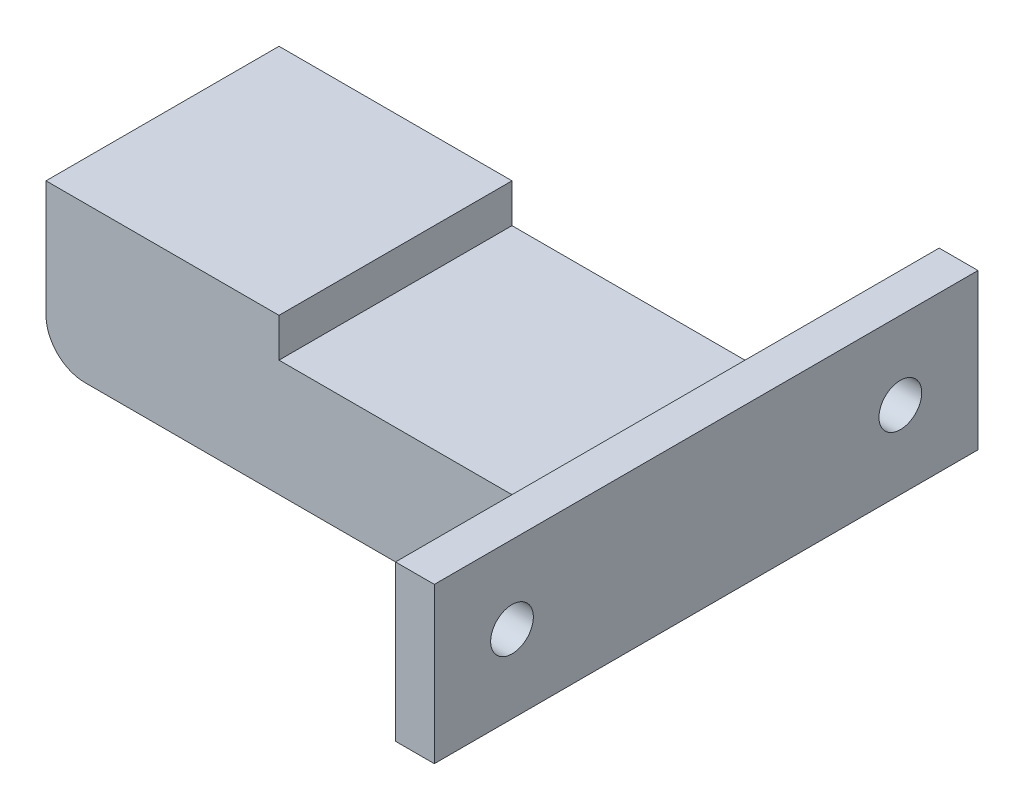
from build123d import *

# Parameters (mm, degrees)
SKETCH1_W           = 70
SKETCH1_H           = 30
BOSS_EXTRUDE1_DEPTH = 20
SKETCH8_W           = 20
SKETCH8_H           = 20
SKETCH8_R           = 2.75
BOSS_EXTRUDE5_DEPTH = 5
FILLET3_R           = 5
SKETCH9_W           = 35
SKETCH9_H           = 40
CUT_EXTRUDE5_DEPTH  = 5


with BuildPart() as part:
    # Sketch1 → Boss-Extrude1 (new body)
    with BuildSketch(Plane(origin=(0, 0, 0), x_dir=(1, 0, 0), z_dir=(0, 1, 0))):
        with Locations((35, 15)):
            Rectangle(SKETCH1_W, SKETCH1_H)
    extrude(amount=BOSS_EXTRUDE1_DEPTH)

    # Sketch8 → Boss-Extrude5 (add)
    with BuildSketch(Plane(origin=(70, 0, 0), x_dir=(0, 0, -1), z_dir=(1, 0, 0))):
        with Locations((-10, 10)):
            Rectangle(SKETCH8_W, SKETCH8_H)
        with Locations((-10, 10)):
            Circle(SKETCH8_R, mode=Mode.SUBTRACT)
    boss_extrude5 = extrude(amount=-BOSS_EXTRUDE5_DEPTH)

    # Mirror1: Boss-Extrude5 across plane
    add(boss_extrude5.mirror(Plane.XY.offset(-15)))

    # Fillet3
    fillet3_edges = [part.edges().sort_by_distance(p)[0] for p in [
        (65, 10, 0),
        (65, 10, -30),
        (0, 0, -15),
    ]]
    fillet(fillet3_edges, radius=FILLET3_R)

    # Sketch9 → Cut-Extrude5 (cut)
    with BuildSketch(Plane(origin=(0, 20, 0), x_dir=(1, 0, 0), z_dir=(0, 1, 0))):
        with Locations((47.5, 15)):
            Rectangle(SKETCH9_W, SKETCH9_H)
    extrude(amount=-CUT_EXTRUDE5_DEPTH, mode=Mode.SUBTRACT)


solid = part.part
